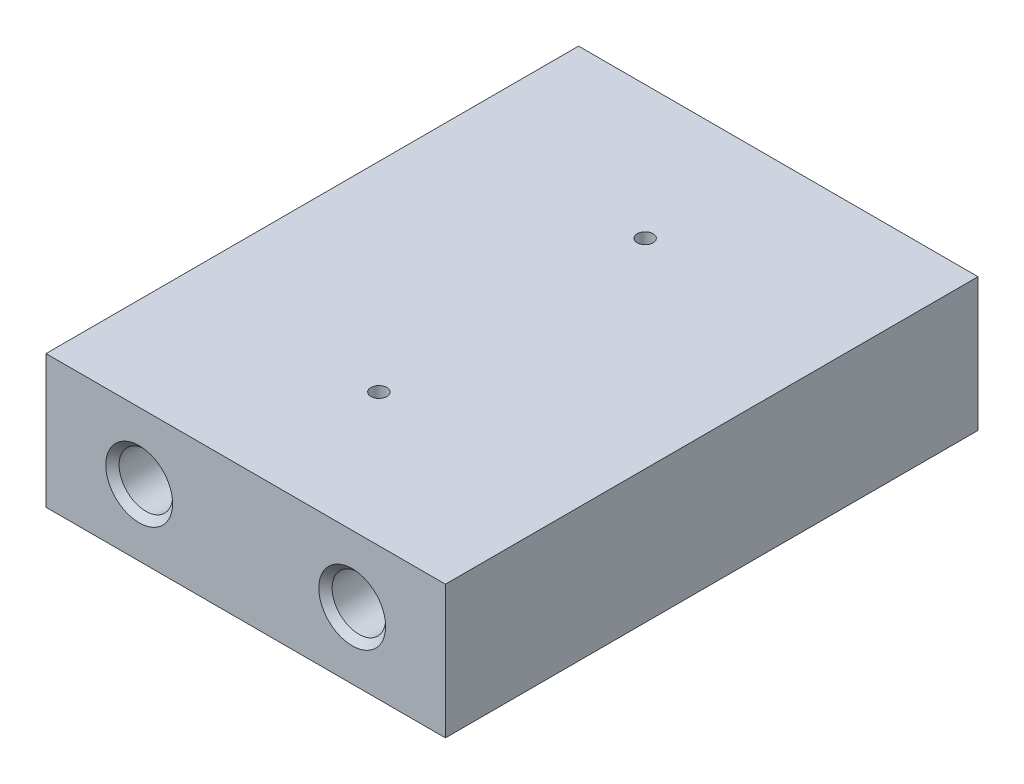
from build123d import *

# Parameters (mm, degrees)
SKETCH1_W                        = 38.1
SKETCH1_H                        = 12.7
BOSS_EXTRUDE1_DEPTH              = 50.8
F_1_4_20_TAPPED_HOLE1_AT_2_COUNT = 2
F_1_4_20_TAPPED_HOLE1_AT_2_PITCH = 20.32
F_1_64_TAPPED_HOLE1_D            = 1.5113
F_1_8_0_125_DIAMETER_HOLE1_D     = 3.175
F_1_8_0_125_DIAMETER_HOLE1_DEPTH = 5.08
F_1_8_0_125_DIAMETER_HOLE1_TIP   = 0.953866233


with BuildPart() as part:
    # Sketch1 → Boss-Extrude1 (new body)
    with BuildSketch(Plane.XY):
        Rectangle(SKETCH1_W, SKETCH1_H)
    extrude(amount=-BOSS_EXTRUDE1_DEPTH)

    # Sketch4 → 1/4-20 Tapped Hole1 (revolve, cut)
    with BuildSketch(Plane(origin=(-10.16, 0, 0), x_dir=(0, -1, 0), z_dir=(1, 0, 0))):
        Polygon((0, 0), (0, 14.233816902), (2.5527, 12.7), (2.5527, 0.635), (3.1877, 0), align=None)
    f_1_4_20_tapped_hole1 = revolve(axis=Axis((-10.16, 0, 6.35), (0, 0, -1)), mode=Mode.SUBTRACT)

    # 1/4-20 Tapped Hole1 at 2: 1/4-20 Tapped Hole1 ×2
    with Locations(*[(i * F_1_4_20_TAPPED_HOLE1_AT_2_PITCH, 0, 0) for i in range(1, F_1_4_20_TAPPED_HOLE1_AT_2_COUNT)]):
        add(f_1_4_20_tapped_hole1, mode=Mode.SUBTRACT)

    # Mirror1: 1/4-20 Tapped Hole1 across plane
    add(f_1_4_20_tapped_hole1.mirror(Plane.XY.offset(-25.4)), mode=Mode.SUBTRACT)

    # Mirror1 copy 1 sketch → Mirror1 copy 1 (revolve, cut)
    with BuildSketch(Plane(origin=(10.16, 0, -50.8), x_dir=(0, -1, 0), z_dir=(1, 0, 0))):
        Polygon((0, 0), (0, -14.233816902), (2.5527, -12.7), (2.5527, -0.635), (3.1877, 0), align=None)
    revolve(axis=Axis((10.16, 0, -57.15), (0, 0, -1)), mode=Mode.SUBTRACT)

    # #1-64 Tapped Hole1 (through all)
    with Locations(Plane(origin=(0, 6.35, -38.1), x_dir=(0, 0, 1), z_dir=(0, 1, 0))):
        with Locations((0, 0), (25.4, 0)):
            Hole(F_1_64_TAPPED_HOLE1_D / 2)

    # 1/8 (0.125) Diameter Hole1
    with Locations(Plane.ZY.offset(19.05)):
        with Locations((-34.29, 0), (-16.51, 0)):
            Hole(F_1_8_0_125_DIAMETER_HOLE1_D / 2, depth=F_1_8_0_125_DIAMETER_HOLE1_DEPTH)
            with Locations((0, 0, -(F_1_8_0_125_DIAMETER_HOLE1_DEPTH + F_1_8_0_125_DIAMETER_HOLE1_TIP / 2))):  # 118° drill point
                Cone(0, F_1_8_0_125_DIAMETER_HOLE1_D / 2, F_1_8_0_125_DIAMETER_HOLE1_TIP, mode=Mode.SUBTRACT)


solid = part.part
